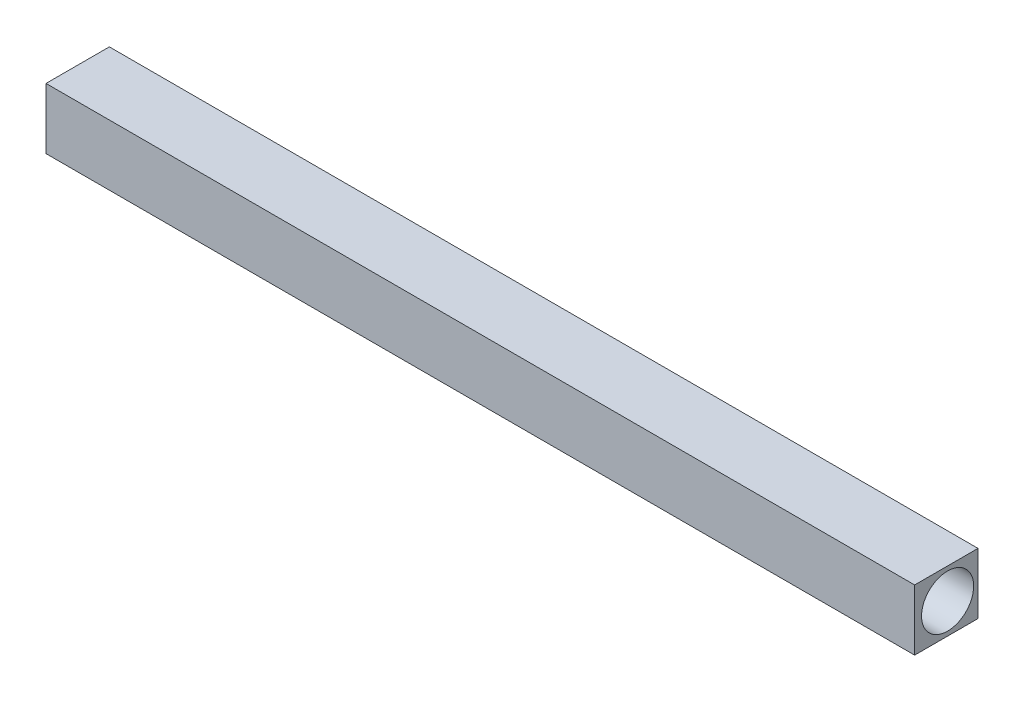
from build123d import *

# Parameters (mm, degrees)
SKETCH1_W           = 500
SKETCH1_H           = 36.458333333
BOSS_EXTRUDE1_DEPTH = 35
SKETCH2_R           = 15
CUT_EXTRUDE1_DEPTH  = 501


with BuildPart() as part:
    # Sketch1 → Boss-Extrude1 (new body)
    with BuildSketch(Plane(origin=(0, 0, 0), x_dir=(1, 0, 0), z_dir=(0, 1, 0))):
        with Locations((190.657487282, -18.229166666)):
            Rectangle(SKETCH1_W, SKETCH1_H)
    extrude(amount=BOSS_EXTRUDE1_DEPTH)

    # Sketch2 → Cut-Extrude1 (cut, through all)
    with BuildSketch(Plane(origin=(440.657487282, 0, 0), x_dir=(0, 0, -1), z_dir=(1, 0, 0))):
        with Locations((-17.5, 17.5)):
            Circle(SKETCH2_R)
    extrude(amount=-CUT_EXTRUDE1_DEPTH, mode=Mode.SUBTRACT)


solid = part.part
